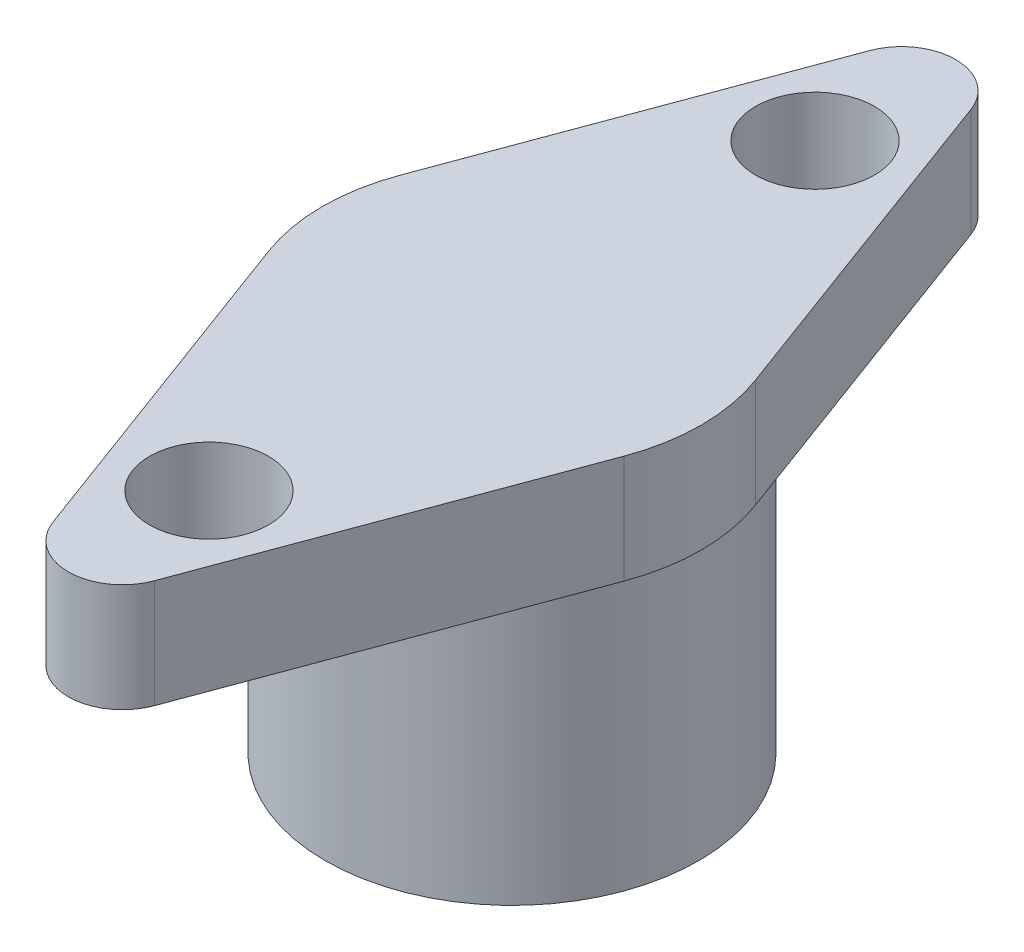
from build123d import *

# Parameters (mm, degrees)
SKETCH1_R           = 3.45
SKETCH1_R_2         = 2.1
BOSS_EXTRUDE1_DEPTH = 5
SKETCH2_R           = 1.1
BOSS_EXTRUDE2_DEPTH = 2


with BuildPart() as part:
    # Sketch1 → Boss-Extrude1 (new body)
    with BuildSketch(Plane(origin=(0, 0, 0), x_dir=(1, 0, 0), z_dir=(0, 1, 0))):
        Circle(SKETCH1_R)
        Circle(SKETCH1_R_2, mode=Mode.SUBTRACT)
    extrude(amount=BOSS_EXTRUDE1_DEPTH)

    # Sketch2 → Boss-Extrude2 (add)
    with BuildSketch(Plane(origin=(0, 5, 0), x_dir=(1, 0, 0), z_dir=(0, 1, 0))):
        with BuildLine():
            Line((-3.282257873, 1.215229712), (-0.937787964, 7.547493269))
            ThreePointArc((-0.937787964, 7.547493269), (0, 8.200284779), (0.937787964, 7.547493269))
            Line((0.937787964, 7.547493269), (3.282257873, 1.215229712))
            ThreePointArc((3.282257873, 1.215229712), (3.5, 0), (3.282257873, -1.215229712))
            Line((3.282257873, -1.215229712), (0.937787964, -7.547493269))
            ThreePointArc((0.937787964, -7.547493269), (0, -8.200284779), (-0.937787964, -7.547493269))
            Line((-0.937787964, -7.547493269), (-3.282257873, -1.215229712))
            ThreePointArc((-3.282257873, -1.215229712), (-3.5, 0), (-3.282257873, 1.215229712))
        make_face()
        with Locations((0, -5.6)):
            Circle(SKETCH2_R, mode=Mode.SUBTRACT)
        with Locations((0, 5.6)):
            Circle(SKETCH2_R, mode=Mode.SUBTRACT)
    extrude(amount=BOSS_EXTRUDE2_DEPTH)


solid = part.part
